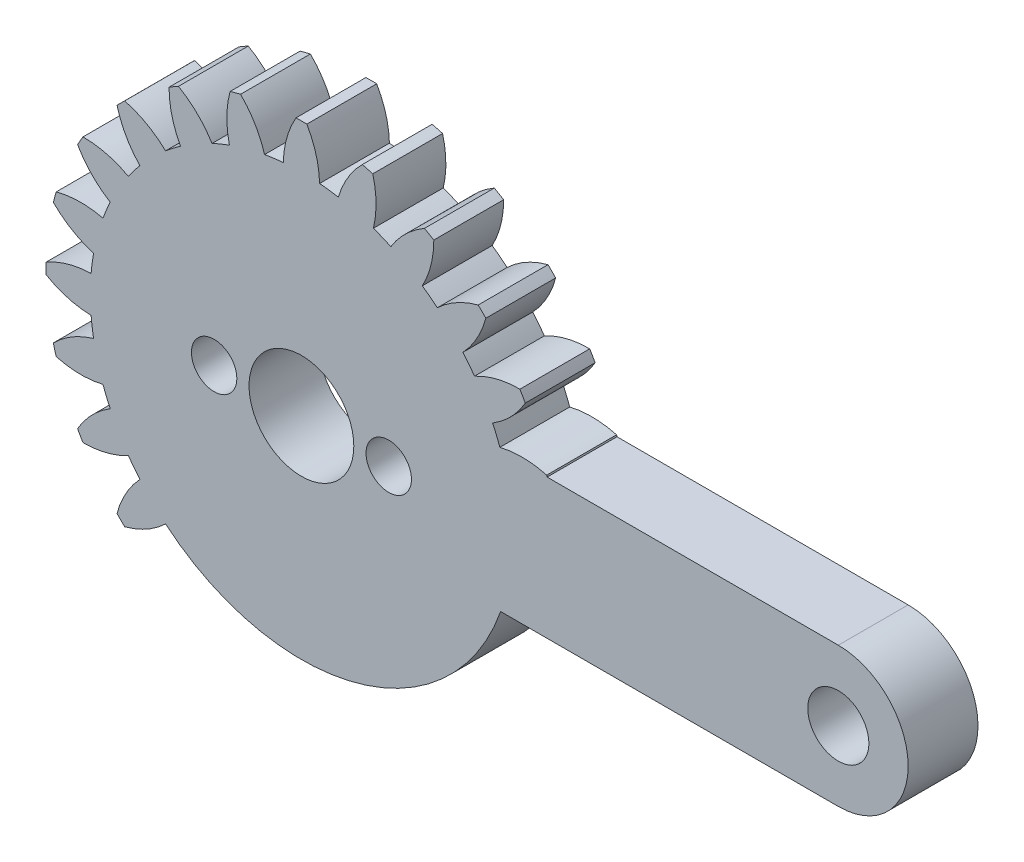
from build123d import *

# Parameters (mm, degrees)
SKETCH1_R           = 1.75
SKETCH1_R_2         = 3
BOSS_EXTRUDE3_DEPTH = 4
SKETCH7_R           = 1.3
CUT_EXTRUDE1_DEPTH  = 5


with BuildPart() as part:
    # Sketch1 → Boss-Extrude3 (new body)
    with BuildSketch(Plane.XY):
        with BuildLine():
            ThreePointArc((30.75, -4), (34.75, 0), (30.75, 4))
            Line((30.75, 4), (14.072558403, 4))
            ThreePointArc((14.072558403, 4), (14.06038767, 4.04257326), (14.048088143, 4.085109489))
            ThreePointArc((14.048088143, 4.085109489), (12.709169027, 4.272836063), (11.365584201, 4.122086336))
            ThreePointArc((11.365584201, 4.122086336), (11.169703548, 4.626642697), (10.951436862, 5.12192646))
            ThreePointArc((10.951436862, 5.12192646), (12.008090957, 5.965388247), (12.82210701, 7.044889767))
            ThreePointArc((12.82210701, 7.044889767), (12.669951657, 7.315), (12.51210701, 7.581825517))
            ThreePointArc((12.51210701, 7.581825517), (11.170223244, 7.416617696), (9.911436862, 6.9232593))
            ThreePointArc((9.911436862, 6.9232593), (9.591641884, 7.359925677), (9.252623584, 7.781841479))
            ThreePointArc((9.252623584, 7.781841479), (10.05496909, 8.870045207), (10.561852666, 10.123446462))
            ThreePointArc((10.561852666, 10.123446462), (10.344972209, 10.344972209), (10.123446462, 10.561852666))
            ThreePointArc((10.123446462, 10.561852666), (8.870045207, 10.05496909), (7.781841479, 9.252623584))
            ThreePointArc((7.781841479, 9.252623584), (7.359925677, 9.591641884), (6.9232593, 9.911436862))
            ThreePointArc((6.9232593, 9.911436862), (7.416617696, 11.170223244), (7.581825517, 12.51210701))
            ThreePointArc((7.581825517, 12.51210701), (7.315, 12.669951657), (7.044889767, 12.82210701))
            ThreePointArc((7.044889767, 12.82210701), (5.965388247, 12.008090957), (5.12192646, 10.951436862))
            ThreePointArc((5.12192646, 10.951436862), (4.626642697, 11.169703548), (4.122086336, 11.365584201))
            ThreePointArc((4.122086336, 11.365584201), (4.272836063, 12.709169027), (4.085109489, 14.048088143))
            ThreePointArc((4.085109489, 14.048088143), (3.78652263, 14.131494839), (3.486235477, 14.208555951))
            ThreePointArc((3.486235477, 14.208555951), (2.654199937, 13.14288127), (2.112960617, 11.903927815))
            ThreePointArc((2.112960617, 11.903927815), (1.578061664, 11.986568374), (1.04, 12.04518576))
            ThreePointArc((1.04, 12.04518576), (0.837867713, 13.382005944), (0.31, 14.626715284))
            ThreePointArc((0.31, 14.626715284), (0, 14.63), (-0.31, 14.626715284))
            ThreePointArc((-0.31, 14.626715284), (-0.837867713, 13.382005944), (-1.04, 12.04518576))
            ThreePointArc((-1.04, 12.04518576), (-1.578061664, 11.986568374), (-2.112960617, 11.903927815))
            ThreePointArc((-2.112960617, 11.903927815), (-2.654199937, 13.14288127), (-3.486235477, 14.208555951))
            ThreePointArc((-3.486235477, 14.208555951), (-3.78652263, 14.131494839), (-4.085109489, 14.048088143))
            ThreePointArc((-4.085109489, 14.048088143), (-4.272836063, 12.709169027), (-4.122086336, 11.365584201))
            ThreePointArc((-4.122086336, 11.365584201), (-4.626642697, 11.169703548), (-5.12192646, 10.951436862))
            ThreePointArc((-5.12192646, 10.951436862), (-5.965388247, 12.008090957), (-7.044889767, 12.82210701))
            ThreePointArc((-7.044889767, 12.82210701), (-7.315, 12.669951657), (-7.581825517, 12.51210701))
            ThreePointArc((-7.581825517, 12.51210701), (-7.416617696, 11.170223244), (-6.9232593, 9.911436862))
            ThreePointArc((-6.9232593, 9.911436862), (-7.359925677, 9.591641884), (-7.781841479, 9.252623584))
            ThreePointArc((-7.781841479, 9.252623584), (-8.870045207, 10.05496909), (-10.123446462, 10.561852666))
            ThreePointArc((-10.123446462, 10.561852666), (-10.344972209, 10.344972209), (-10.561852666, 10.123446462))
            ThreePointArc((-10.561852666, 10.123446462), (-10.05496909, 8.870045207), (-9.252623584, 7.781841479))
            ThreePointArc((-9.252623584, 7.781841479), (-9.591641884, 7.359925677), (-9.911436862, 6.9232593))
            ThreePointArc((-9.911436862, 6.9232593), (-11.170223244, 7.416617696), (-12.51210701, 7.581825517))
            ThreePointArc((-12.51210701, 7.581825517), (-12.669951657, 7.315), (-12.82210701, 7.044889767))
            ThreePointArc((-12.82210701, 7.044889767), (-12.008090957, 5.965388247), (-10.951436862, 5.12192646))
            ThreePointArc((-10.951436862, 5.12192646), (-11.169703548, 4.626642697), (-11.365584201, 4.122086336))
            ThreePointArc((-11.365584201, 4.122086336), (-12.709169027, 4.272836063), (-14.048088143, 4.085109489))
            ThreePointArc((-14.048088143, 4.085109489), (-14.131494839, 3.78652263), (-14.208555951, 3.486235477))
            ThreePointArc((-14.208555951, 3.486235477), (-13.14288127, 2.654199937), (-11.903927815, 2.112960617))
            ThreePointArc((-11.903927815, 2.112960617), (-11.986568374, 1.578061664), (-12.04518576, 1.04))
            ThreePointArc((-12.04518576, 1.04), (-13.382005944, 0.837867713), (-14.626715284, 0.31))
            ThreePointArc((-14.626715284, 0.31), (-14.63, 0), (-14.626715284, -0.31))
            ThreePointArc((-14.626715284, -0.31), (-13.382005944, -0.837867713), (-12.04518576, -1.04))
            ThreePointArc((-12.04518576, -1.04), (-11.986568374, -1.578061664), (-11.903927815, -2.112960617))
            ThreePointArc((-11.903927815, -2.112960617), (-13.14288127, -2.654199937), (-14.208555951, -3.486235477))
            ThreePointArc((-14.208555951, -3.486235477), (-14.131494839, -3.78652263), (-14.048088143, -4.085109489))
            ThreePointArc((-14.048088143, -4.085109489), (-12.709169027, -4.272836063), (-11.365584201, -4.122086336))
            ThreePointArc((-11.365584201, -4.122086336), (-11.169703548, -4.626642697), (-10.951436862, -5.12192646))
            ThreePointArc((-10.951436862, -5.12192646), (-12.008090957, -5.965388247), (-12.82210701, -7.044889767))
            ThreePointArc((-12.82210701, -7.044889767), (-12.669951657, -7.315), (-12.51210701, -7.581825517))
            ThreePointArc((-12.51210701, -7.581825517), (-11.170223244, -7.416617696), (-9.911436862, -6.9232593))
            ThreePointArc((-9.911436862, -6.9232593), (-9.591641884, -7.359925677), (-9.252623584, -7.781841479))
            ThreePointArc((-9.252623584, -7.781841479), (-10.05496909, -8.870045207), (-10.561852666, -10.123446462))
            ThreePointArc((-10.561852666, -10.123446462), (-10.344972209, -10.344972209), (-10.123446462, -10.561852666))
            ThreePointArc((-10.123446462, -10.561852666), (-8.870045207, -10.05496909), (-7.781841479, -9.252623584))
            ThreePointArc((-7.781841479, -9.252623584), (3.191677838, -11.661101688), (11.409123542, -4))
            Line((11.409123542, -4), (30.75, -4))
        make_face()
        with Locations((30.75, 0)):
            Circle(SKETCH1_R, mode=Mode.SUBTRACT)
        Circle(SKETCH1_R_2, mode=Mode.SUBTRACT)
    extrude(amount=BOSS_EXTRUDE3_DEPTH)

    # Sketch7 → Cut-Extrude1 (cut, through all)
    with BuildSketch(Plane.XY.offset(4)):
        with Locations((5, 0)):
            Circle(SKETCH7_R)
        with Locations((-5, 0)):
            Circle(SKETCH7_R)
    extrude(amount=-CUT_EXTRUDE1_DEPTH, mode=Mode.SUBTRACT)


solid = part.part
